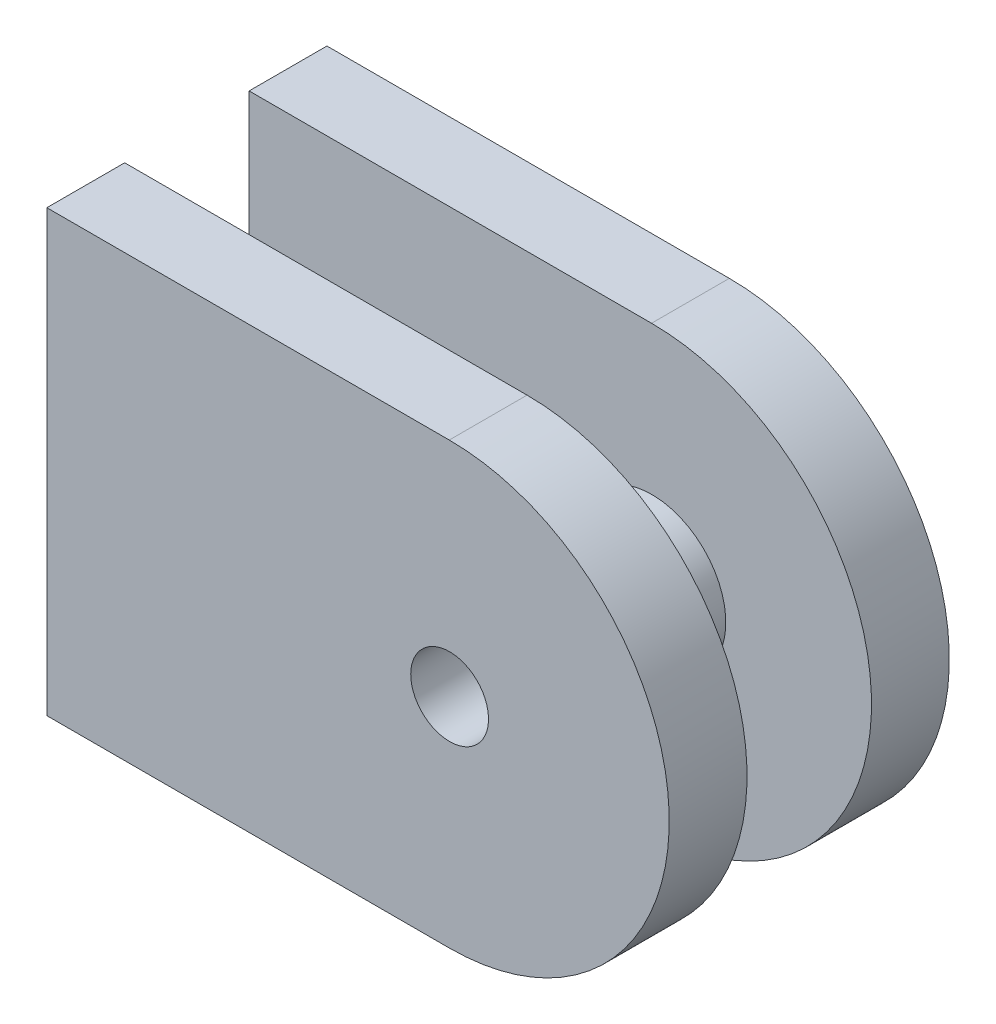
from build123d import *

# Parameters (mm, degrees)
SKETCH2_W               = 40
SKETCH2_H               = 35
BOSS_EXTRUDE1_DEPTH     = 5
SKETCH4_R               = 4.75
BOSS_EXTRUDE2_DEPTH     = 8
SKETCH6_OUTSIDE_W       = 53.224
SKETCH6_OUTSIDE_H       = 48.224
CUT_EXTRUDE2_DEPTH      = 20
CUT_EXTRUDE2_DEPTH_BACK = 20
M6X1_0_TAPPED_HOLE1_D   = 5


with BuildPart() as part:
    # Sketch2 → Boss-Extrude1 (new body)
    with BuildSketch(Plane.XY):
        with Locations((20, 17.5)):
            Rectangle(SKETCH2_W, SKETCH2_H)
    extrude(amount=BOSS_EXTRUDE1_DEPTH)

    # Sketch4 → Boss-Extrude2 (add)
    with BuildSketch(Plane.XY.offset(5)):
        with Locations((25.885379028, 17.5)):
            Circle(SKETCH4_R)
    extrude(amount=BOSS_EXTRUDE2_DEPTH)

    # Mirror4: part across plane


with BuildPart() as part_1:
    add(part.part)
    add(part.part.mirror(Plane.XY.offset(9)))

    # Sketch6 outside → Cut-Extrude2 (cut, two sides)
    with BuildSketch(Plane.XY.offset(5)) as cut_extrude2_sk:
        with Locations((20, 17.5)):
            Rectangle(SKETCH6_OUTSIDE_W, SKETCH6_OUTSIDE_H)
        with BuildLine():
            Line((25.86267887, 31.77132519), (0, 31.77132519))
            Line((0, 31.77132519), (0, 3.496682929))
            Line((0, 3.496682929), (25.86267887, 3.496682929))
            ThreePointArc((25.86267887, 3.496682929), (40, 17.63400406), (25.86267887, 31.77132519))
        make_face(mode=Mode.SUBTRACT)
    extrude(amount=CUT_EXTRUDE2_DEPTH, mode=Mode.SUBTRACT)
    extrude(cut_extrude2_sk.sketch, amount=-CUT_EXTRUDE2_DEPTH_BACK, mode=Mode.SUBTRACT)

    # M6x1.0 Tapped Hole1 (through all)
    with Locations(Plane(origin=(0, 0, 0), x_dir=(-1, 0, 0), z_dir=(0, 0, -1))):
        with Locations((-25.885379028, 17.5)):
            Hole(M6X1_0_TAPPED_HOLE1_D / 2)


solid = part_1.part
